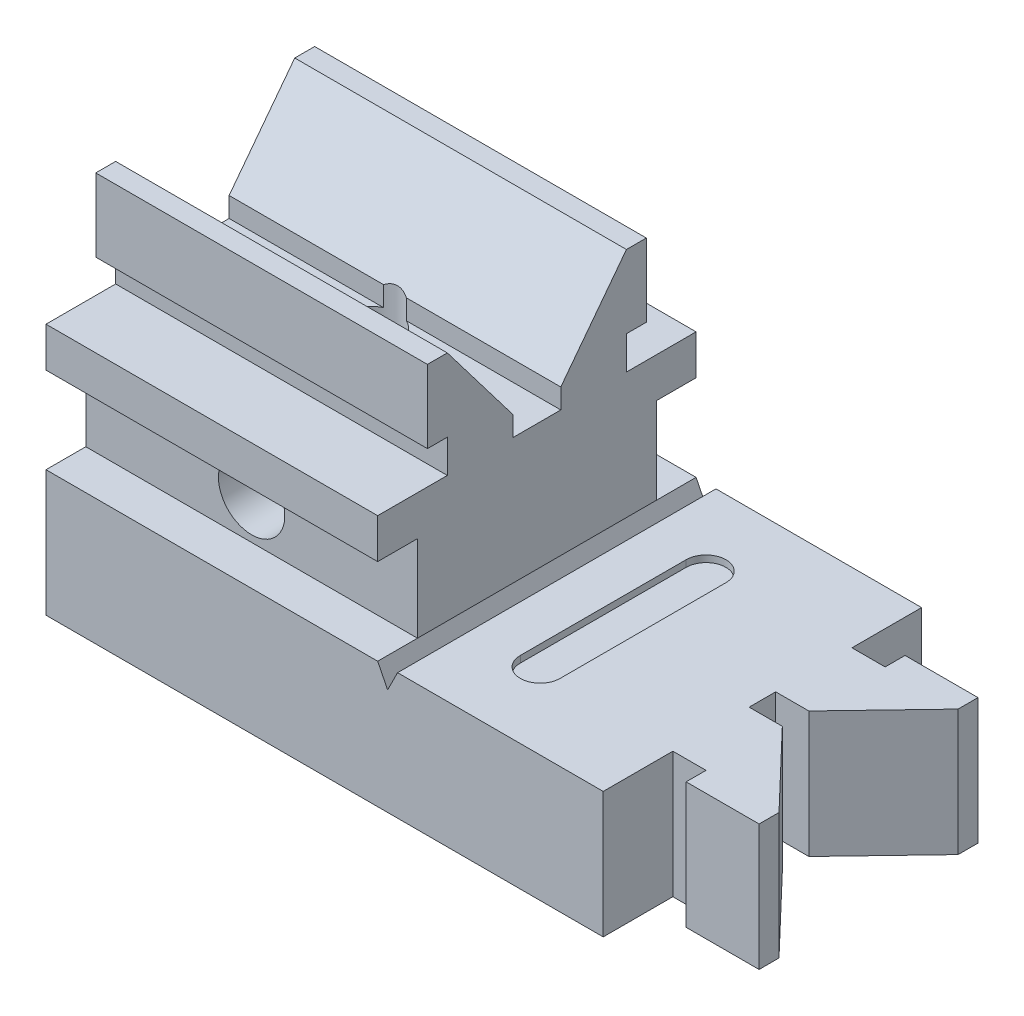
from build123d import *

# Parameters (mm, degrees)
BOSS_EXTRUDE2_DEPTH     = 24
BOSS_EXTRUDE3_DEPTH     = 19
CUT_EXTRUDE1_DEPTH      = 1
BOSS_EXTRUDE4_DEPTH     = 50
SKETCH5_R               = 4
CUT_EXTRUDE2_DEPTH      = 55
SKETCH6_R               = 5
CUT_EXTRUDE3_DEPTH      = 25
CUT_EXTRUDE3_DEPTH_BACK = 25


with BuildPart() as part:
    # Sketch1 → Boss-Extrude2 (new body, symmetric)
    with BuildSketch(Plane.XY):
        Polygon((0, 0), (84, 0), (84, 19), (53, 19), (51.5, 16), (50, 19), (0, 19), align=None)
    extrude(amount=BOSS_EXTRUDE2_DEPTH, both=True)

    # Sketch2 → Boss-Extrude3 (add)
    with BuildSketch(Plane(origin=(0, 0, 0), x_dir=(1, 0, 0), z_dir=(0, 1, 0))):
        Polygon((84, 2), (89, 2), (100, 13.5), (100, 16.5), (89, 16.5), (89, 13.5), (84, 13.5), align=None)
    boss_extrude3 = extrude(amount=BOSS_EXTRUDE3_DEPTH)

    # Mirror1: Boss-Extrude3 across plane
    add(boss_extrude3.mirror(Plane.XY))

    # Sketch3 → Cut-Extrude1 (cut)
    with BuildSketch(Plane(origin=(0, 19, 0), x_dir=(1, 0, 0), z_dir=(0, 1, 0))):
        with BuildLine():
            Line((66, 12.5), (66, -12.5))
            ThreePointArc((66, -12.5), (63, -15.5), (60, -12.5))
            Line((60, -12.5), (60, 12.5))
            ThreePointArc((60, 12.5), (63, 15.5), (66, 12.5))
        make_face()
    extrude(amount=-CUT_EXTRUDE1_DEPTH, mode=Mode.SUBTRACT)

    # Sketch4 → Boss-Extrude4 (add)
    with BuildSketch(Plane(origin=(0, 0, 0), x_dir=(0, 0, -1), z_dir=(1, 0, 0))):
        Polygon((-18, 19), (-18, 32), (-24, 32), (-24, 38), (-13.5, 38), (-13.5, 43), (-16.5, 43), (-16.5, 54), (-13.5, 54), (-3.604820816, 41), (-3.604820816, 38), (0, 38), (0, 19), align=None)
    boss_extrude4 = extrude(amount=BOSS_EXTRUDE4_DEPTH)

    # Mirror2: Boss-Extrude4 across plane
    add(boss_extrude4.mirror(Plane.XY))

    # Sketch5 → Cut-Extrude2 (cut, through all)
    with BuildSketch(Plane(origin=(0, 0, 0), x_dir=(1, 0, 0), z_dir=(0, 1, 0))):
        with Locations((25, 0)):
            Circle(SKETCH5_R)
    extrude(amount=CUT_EXTRUDE2_DEPTH, mode=Mode.SUBTRACT)

    # Sketch6 → Cut-Extrude3 (cut, two sides)
    with BuildSketch(Plane.XY) as cut_extrude3_sk:
        with Locations((25, 25)):
            Circle(SKETCH6_R)
    extrude(amount=CUT_EXTRUDE3_DEPTH, mode=Mode.SUBTRACT)
    extrude(cut_extrude3_sk.sketch, amount=-CUT_EXTRUDE3_DEPTH_BACK, mode=Mode.SUBTRACT)


solid = part.part
